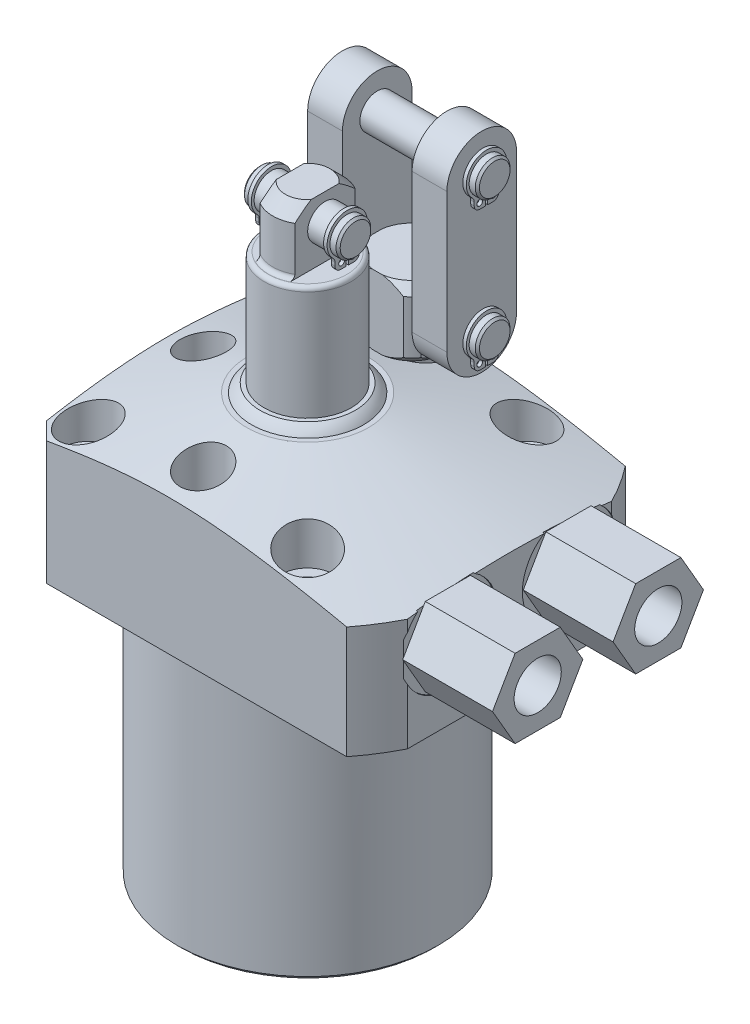
from build123d import *

# Parameters (mm, degrees)
SKETCH3_OUTSIDE_W          = 112.432
SKETCH3_OUTSIDE_H          = 112.432
SKETCH3_OUTSIDE_W_2        = 62.23
SKETCH3_OUTSIDE_H_2        = 50.8
CUT_EXTRUDE9_DEPTH         = 76.2
CHAMFER8_SIZE              = 3.175
CHAMFER5_SIZE              = 0.762
HOLE1_D                    = 5.5626
HOLE1_DEPTH                = 28.575
HOLE1_CBORE_D              = 9.525
HOLE1_CBORE_DEPTH          = 11.0998
SKETCH34_R                 = 4.2164
CUT_EXTRUDE10_DEPTH        = 12.7
EXTRUDE14_DEPTH            = 16.383
HOLE2_D                    = 8.6106
HOLE2_DEPTH                = 6.7056
SKETCH33_R                 = 0.889
CUT_EXTRUDE7_DEPTH         = 11.0998
FILLET4_R                  = 0.762
SKETCH29_R                 = 3.16865
EXTRUDE11_DEPTH            = 8.7249
EXTRUDE2_START             = -1.4986
SKETCH16_R                 = 0.5207
EXTRUDE2_DEPTH             = 0.635
CHAMFER6_SIZE              = 0.381
CUT_EXTRUDE11_DEPTH        = 12.7
SKETCH30_R                 = 3.16865
EXTRUDE12_DEPTH            = 15.0749
EXTRUDE4_START             = -1.4986
SKETCH19_R                 = 0.5207
EXTRUDE4_DEPTH             = 0.635
EXTRUDE13_DEPTH            = 6.35
CHAMFER7_SIZE              = 0.381
LPATTERN2_COUNT            = 2
LPATTERN2_PITCH            = 25.4
LPATTERN2_START            = -1.4986
LPATTERN2_COPY_1_SKETCH_R  = 0.5207
LPATTERN2_COPY_1_DEPTH     = 0.635
CHAMFER7_OF_LPATTERN2_SIZE = 0.381


with BuildPart() as part:
    # Sketch28 → Revolve7 (revolve)
    with BuildSketch(Plane.XY, mode=Mode.PRIVATE) as revolve7_sk:
        Polygon((-11.1125, 28.575), (-41.275, 20.492982483), (-41.275, 0), (-23.8125, 0), (-23.8125, -47.625), (0, -47.625), (0, 28.575), align=None)
    revolve(revolve7_sk.sketch.rotate(Axis((0, 0, 0), (0, 1, 0)), 270), axis=Axis((0, 0, 0), (0, 1, 0)))  # turned: the seam where the file's is

    # Sketch3 outside → Cut-Extrude9 (cut)
    with BuildSketch(Plane(origin=(0, 28.575, 0), x_dir=(-1, 0, 0), z_dir=(0, 1, 0))):
        Rectangle(SKETCH3_OUTSIDE_W, SKETCH3_OUTSIDE_H)
        with Locations((-5.715, 0)):
            Rectangle(SKETCH3_OUTSIDE_W_2, SKETCH3_OUTSIDE_H_2, mode=Mode.SUBTRACT)
    extrude(amount=-CUT_EXTRUDE9_DEPTH, mode=Mode.SUBTRACT)

    # Chamfer8
    chamfer8_edges = [part.edges().sort_by_distance(p)[0] for p in [
        (-25.4, 10.96378795, -25.4),
        (-25.4, 10.96378795, 25.4),
    ]]
    chamfer(chamfer8_edges, length=CHAMFER8_SIZE)

    # Chamfer5
    chamfer5_edges = [part.edges().sort_by_distance(p)[0] for p in [
        (0, -47.625, 23.8125),
    ]]
    chamfer(chamfer5_edges, length=CHAMFER5_SIZE)

    # Hole1
    with Locations(Plane(origin=(0, 28.575, 0), x_dir=(-1, 0, 0), z_dir=(0, 1, 0))):
        with Locations((-20.0025, -20.0025), (-20.0025, 20.0025), (20.0025, -20.0025), (20.0025, 20.0025)):
            CounterBoreHole(HOLE1_D / 2, HOLE1_CBORE_D / 2, HOLE1_CBORE_DEPTH, depth=HOLE1_DEPTH)

    # Sketch34 → Cut-Extrude10 (cut)
    with BuildSketch(Plane(origin=(0, 28.575, 0), x_dir=(1, 0, 0), z_dir=(0, 1, 0))):
        with Locations(Location((0, 19.05, 0), (0, 0, 270))):  # turned: the seam where the file's is
            Circle(SKETCH34_R)
        with Locations(Location((0, -19.05, 0), (0, 0, 133.869906741))):  # turned: the seam where the file's is
            Circle(SKETCH34_R)
        with Locations(Location((-19.05, 0, 0), (0, 0, 270))):  # turned: the seam where the file's is
            Circle(SKETCH34_R)
    extrude(amount=-CUT_EXTRUDE10_DEPTH, mode=Mode.SUBTRACT)

    # S2D0007 → Cut-Revolve2 (revolve, cut)
    with BuildSketch(Plane.XZ.offset(-14.2748)):
        Polygon((36.83, -10.9982), (36.83, -19.6596), (36.576, -19.6596), (36.576, -15.57655), (34.5059, -15.136536662), (33.821963338, -14.4526), (24.384, -14.4526), (22.308387078, -10.9982), align=None)
    cut_revolve2 = revolve(axis=Axis((-11.746808274, 14.2748, -10.9982), (-1, 0, 0)), mode=Mode.SUBTRACT)

    # Sketch6 → Cut-Revolve3 (revolve, cut)
    with BuildSketch(Plane.XY.offset(-10.9982), mode=Mode.PRIVATE) as cut_revolve3_sk:
        with BuildLine():
            Line((35.66795, 0), (35.66795, 1.4478))
            Line((35.66795, 1.4478), (32.60745581, 1.4478))
            ThreePointArc((32.60745581, 1.4478), (31.925854622, 0.917608896), (31.1404, 0.5588))
            Line((31.1404, 0.5588), (29.9974, 0.5588))
            Line((29.9974, 0.5588), (29.9974, 0))
            Line((29.9974, 0), (35.66795, 0))
        make_face()
    cut_revolve3 = revolve(cut_revolve3_sk.sketch.rotate(Axis((29.9974, -21.049171587, -10.9982), (0, 1, 0)), 90), axis=Axis((29.9974, -21.049171587, -10.9982), (0, 1, 0)), mode=Mode.SUBTRACT)  # turned: the seam where the file's is

    # Sketch39 → Extrude14 (add)
    with BuildSketch(Plane(origin=(36.576, 0, 0), x_dir=(0, 0, -1), z_dir=(1, 0, 0))):
        Polygon((19.239759623, 14.2748), (15.118979811, 21.4122), (6.877420189, 21.4122), (2.756640377, 14.2748), (6.877420189, 7.1374), (15.118979811, 7.1374), align=None)
    extrude14 = extrude(amount=EXTRUDE14_DEPTH)

    # Hole2
    with Locations(Plane(origin=(52.959, 0, 0), x_dir=(0, 0, -1), z_dir=(1, 0, 0))):
        with Locations((10.9982, 14.2748)):
            hole2 = Hole(HOLE2_D / 2, depth=HOLE2_DEPTH)

    # Mirror6: Cut-Revolve2, Cut-Revolve3, Extrude14, Hole2 across plane
    add(cut_revolve2.mirror(Plane.XY), mode=Mode.SUBTRACT)
    add(cut_revolve3.mirror(Plane.XY), mode=Mode.SUBTRACT)
    add(extrude14.mirror(Plane.XY))
    add(hole2.mirror(Plane.XY), mode=Mode.SUBTRACT)

    # Sketch12 → Revolve2 (revolve)
    with BuildSketch(Plane(origin=(0, 0, 0), x_dir=(-1, 0, 0), z_dir=(0, 0, -1)), mode=Mode.PRIVATE) as revolve2_sk:
        with BuildLine():
            Line((0, 28.575), (0, 30.099))
            Line((0, 30.099), (8.6995, 30.099))
            ThreePointArc((8.6995, 30.099), (9.549082922, 29.424582922), (10.2235, 28.575))
            Line((10.2235, 28.575), (0, 28.575))
        make_face()
    revolve(revolve2_sk.sketch.rotate(Axis((0, 22.10562, 0), (0, 1, 0)), 270), axis=Axis((0, 22.10562, 0), (0, 1, 0)))  # turned: the seam where the file's is

    # Sketch13 → Revolve3 (revolve)
    with BuildSketch(Plane.XY, mode=Mode.PRIVATE) as revolve3_sk:
        Polygon((0, 30.099), (0, 61.8998), (4.064, 61.8998), (6.35, 59.6138), (6.35, 50.8), (7.93115, 50.8), (7.93115, 30.099), align=None)
    revolve(revolve3_sk.sketch.rotate(Axis((0, 23.02637, 0), (0, 1, 0)), 90), axis=Axis((0, 23.02637, 0), (0, 1, 0)))  # turned: the seam where the file's is

    # Sketch14 → Cut-Extrude7 (cut)
    with BuildSketch(Plane(origin=(0, 61.8998, 0), x_dir=(-1, 0, 0), z_dir=(0, 1, 0))):
        with BuildLine():
            Line((3.175, 5.499261314), (3.175, -5.499261314))
            ThreePointArc((3.175, -5.499261314), (6.35, 0), (3.175, 5.499261314))
        make_face()
        with BuildLine():
            Line((-3.175, -5.499261314), (-3.175, 5.499261314))
            ThreePointArc((-3.175, 5.499261314), (-6.35, 0), (-3.175, -5.499261314))
        make_face()
    extrude(amount=-CUT_EXTRUDE7_DEPTH, mode=Mode.SUBTRACT)

    # Fillet4
    fillet4_edges = [part.edges().sort_by_distance(p)[0] for p in [
        (0, 50.8, 7.93115),
        (0, 50.8, -6.35),
        (0, 50.8, 6.35),
    ]]
    fillet(fillet4_edges, radius=FILLET4_R)

    # Sketch29 → Extrude11 (add, symmetric)
    with BuildSketch(Plane.ZY):
        with Locations((0, 57.15)):
            Circle(SKETCH29_R)
    extrude(amount=EXTRUDE11_DEPTH, both=True)

    # Sketch16 → Extrude2 (add)
    with BuildSketch(Plane(origin=(-8.7249, 52.3748, 0), x_dir=(0, 0, 1), z_dir=(-1, 0, 0)).offset(EXTRUDE2_START)):
        with BuildLine():
            Line((0.20828, 1.861635097), (0.20828, -0.170364903))
            Line((0.20828, -0.170364903), (1.19888, -0.170364903))
            ThreePointArc((1.19888, -0.170364903), (1.935261002, 0.134654095), (2.24028, 0.871035097))
            Line((2.24028, 0.871035097), (2.24028, 1.503592677))
            ThreePointArc((2.24028, 1.503592677), (2.323076064, 1.910523204), (2.558298925, 2.252748054))
            ThreePointArc((2.558298925, 2.252748054), (0, 8.5852), (-2.558298925, 2.252748054))
            ThreePointArc((-2.558298925, 2.252748054), (-2.323076064, 1.910523204), (-2.24028, 1.503592677))
            Line((-2.24028, 1.503592677), (-2.24028, 0.871035097))
            ThreePointArc((-2.24028, 0.871035097), (-1.935261002, 0.134654095), (-1.19888, -0.170364903))
            Line((-1.19888, -0.170364903), (-0.20828, -0.170364903))
            Line((-0.20828, -0.170364903), (-0.20828, 1.861635097))
            ThreePointArc((-0.20828, 1.861635097), (0, 7.6962), (0.20828, 1.861635097))
        make_face()
        with Locations((1.0414, 0.871035097)):
            Circle(SKETCH16_R, mode=Mode.SUBTRACT)
        with Locations(Location((-1.0414, 0.871035097, 0), (0, 0, 180))):  # turned: the seam where the file's is
            Circle(SKETCH16_R, mode=Mode.SUBTRACT)
    extrude2 = extrude(amount=-EXTRUDE2_DEPTH)

    # Chamfer6
    chamfer6_edges = [part.edges().sort_by_distance(p)[0] for p in [
        (8.7249, 57.15, -3.16865),
        (-8.7249, 57.15, -3.16865),
    ]]
    chamfer(chamfer6_edges, length=CHAMFER6_SIZE)

    # Mirror2: Extrude2 across plane
    add(extrude2.mirror(Plane.ZY))

    # Sketch35 → Revolve10 (revolve)
    with BuildSketch(Plane.ZY):
        Polygon((-19.05, 15.875), (-14.2875, 15.875), (-14.2875, 28.575), (-12.6365, 28.575), (-11.1125, 30.099), (-11.1125, 39.751), (-12.6365, 41.275), (-19.05, 41.275), align=None)
    revolve(axis=Axis((0, 43.57409058, -19.05), (0, -1, 0)))

    # Sketch36 → Cut-Extrude11 (cut)
    with BuildSketch(Plane(origin=(0, 41.275, 0), x_dir=(1, 0, 0), z_dir=(0, 1, 0))):
        with BuildLine():
            Line((6.35, 23.8125), (6.35, 14.2875))
            ThreePointArc((6.35, 14.2875), (7.9375, 19.05), (6.35, 23.8125))
        make_face()
        with BuildLine():
            Line((4.7625, 25.4), (-4.7625, 25.4))
            ThreePointArc((-4.7625, 25.4), (0, 26.9875), (4.7625, 25.4))
        make_face()
        with BuildLine():
            Line((-6.35, 23.8125), (-6.35, 14.2875))
            ThreePointArc((-6.35, 14.2875), (-7.9375, 19.05), (-6.35, 23.8125))
        make_face()
        with BuildLine():
            Line((4.7625, 12.7), (-4.7625, 12.7))
            ThreePointArc((-4.7625, 12.7), (0, 11.1125), (4.7625, 12.7))
        make_face()
    extrude(amount=-CUT_EXTRUDE11_DEPTH, mode=Mode.SUBTRACT)

    # Sketch30 → Extrude12 (add, symmetric)
    with BuildSketch(Plane.ZY):
        with Locations((-19.05, 34.925)):
            Circle(SKETCH30_R)
    extrude12 = extrude(amount=EXTRUDE12_DEPTH, both=True)

    # Sketch19 → Extrude4 (add)
    with BuildSketch(Plane(origin=(-15.0749, 11.0998, -22.225), x_dir=(0, 0, 1), z_dir=(-1, 0, 0)).offset(EXTRUDE4_START)):
        with BuildLine():
            Line((3.38328, 20.911635097), (3.38328, 18.879635097))
            Line((3.38328, 18.879635097), (4.37388, 18.879635097))
            ThreePointArc((4.37388, 18.879635097), (5.110261002, 19.184654095), (5.41528, 19.921035097))
            Line((5.41528, 19.921035097), (5.41528, 20.553592677))
            ThreePointArc((5.41528, 20.553592677), (5.498076064, 20.960523204), (5.733298925, 21.302748054))
            ThreePointArc((5.733298925, 21.302748054), (3.175, 27.6352), (0.616701075, 21.302748054))
            ThreePointArc((0.616701075, 21.302748054), (0.851923936, 20.960523204), (0.93472, 20.553592677))
            Line((0.93472, 20.553592677), (0.93472, 19.921035097))
            ThreePointArc((0.93472, 19.921035097), (1.239738998, 19.184654095), (1.97612, 18.879635097))
            Line((1.97612, 18.879635097), (2.96672, 18.879635097))
            Line((2.96672, 18.879635097), (2.96672, 20.911635097))
            ThreePointArc((2.96672, 20.911635097), (3.175, 26.7462), (3.38328, 20.911635097))
        make_face()
        with Locations((4.42468, 19.921035097)):
            Circle(SKETCH19_R, mode=Mode.SUBTRACT)
        with Locations(Location((1.92532, 19.921035097, 0), (0, 0, 180))):  # turned: the seam where the file's is
            Circle(SKETCH19_R, mode=Mode.SUBTRACT)
    extrude4 = extrude(amount=-EXTRUDE4_DEPTH)

    # Sketch37 → Extrude13 (add)
    with BuildSketch(Plane.ZY.offset(6.35)):
        with BuildLine():
            Line((-25.400000096, 60.324999976), (-25.4, 34.924999976))
            ThreePointArc((-25.4, 34.924999976), (-19.049999976, 28.575), (-12.7, 34.925000024))
            Line((-12.7, 34.925000024), (-12.700000096, 60.325000024))
            ThreePointArc((-12.700000096, 60.325000024), (-19.05000012, 66.675), (-25.400000096, 60.324999976))
        make_face()
    extrude13 = extrude(amount=EXTRUDE13_DEPTH)

    # Mirror3: Extrude4 across plane
    add(extrude4.mirror(Plane.ZY))

    # Chamfer7
    chamfer7_edges = [part.edges().sort_by_distance(p)[0] for p in [
        (15.0749, 34.925, -22.21865),
        (-15.0749, 34.925, -22.21865),
    ]]
    chamfer(chamfer7_edges, length=CHAMFER7_SIZE)

    # LPattern2: Extrude4, Extrude12 ×2
    with Locations(*[(0, i * LPATTERN2_PITCH, 0) for i in range(1, LPATTERN2_COUNT)]):
        add(extrude4)
        add(extrude12)

    # LPattern2 copy 1 sketch → LPattern2 copy 1 (add)
    with BuildSketch(Plane(origin=(15.0749, 36.4998, -22.225000096), x_dir=(0, 0, 1), z_dir=(1, 0, 0)).offset(LPATTERN2_START)):
        with BuildLine():
            Line((3.38328, -20.911635097), (3.38328, -18.879635097))
            Line((3.38328, -18.879635097), (4.37388, -18.879635097))
            ThreePointArc((4.37388, -18.879635097), (5.110261002, -19.184654095), (5.41528, -19.921035097))
            Line((5.41528, -19.921035097), (5.41528, -20.553592677))
            ThreePointArc((5.41528, -20.553592677), (5.498076064, -20.960523204), (5.733298925, -21.302748054))
            ThreePointArc((5.733298925, -21.302748054), (3.175, -27.6352), (0.616701075, -21.302748054))
            ThreePointArc((0.616701075, -21.302748054), (0.851923936, -20.960523204), (0.93472, -20.553592677))
            Line((0.93472, -20.553592677), (0.93472, -19.921035097))
            ThreePointArc((0.93472, -19.921035097), (1.239738998, -19.184654095), (1.97612, -18.879635097))
            Line((1.97612, -18.879635097), (2.96672, -18.879635097))
            Line((2.96672, -18.879635097), (2.96672, -20.911635097))
            ThreePointArc((2.96672, -20.911635097), (3.175, -26.7462), (3.38328, -20.911635097))
        make_face()
        with Locations((4.42468, -19.921035097)):
            Circle(LPATTERN2_COPY_1_SKETCH_R, mode=Mode.SUBTRACT)
        with Locations((1.92532, -19.921035097)):
            Circle(LPATTERN2_COPY_1_SKETCH_R, mode=Mode.SUBTRACT)
    extrude(amount=-LPATTERN2_COPY_1_DEPTH)

    # Chamfer7 of LPattern2
    chamfer7_of_lpattern2_edges = [part.edges().sort_by_distance(p)[0] for p in [
        (15.0749, 60.325, -22.218650096),
        (-15.0749, 60.325, -22.218650096),
    ]]
    chamfer(chamfer7_of_lpattern2_edges, length=CHAMFER7_OF_LPATTERN2_SIZE)

    # Mirror8: Extrude13 across plane
    add(extrude13.mirror(Plane.ZY))


with BuildPart() as body_2:
    # Sketch33 → Revolve9 (revolve)
    with BuildSketch(Plane.XY.offset(-10.9982), mode=Mode.PRIVATE) as revolve9_sk:
        with Locations((25.21585, 0.5842)):
            Circle(SKETCH33_R)
    revolve(revolve9_sk.sketch.rotate(Axis((29.9974, 8.329668034, -10.9982), (0, -1, 0)), 90), axis=Axis((29.9974, 8.329668034, -10.9982), (0, -1, 0)))  # turned: the seam where the file's is


with BuildPart() as body_3:
    # Mirror7: mirrored copy
    add(body_2.part.mirror(Plane.XY))


solid = Compound([part.part, body_2.part, body_3.part])
